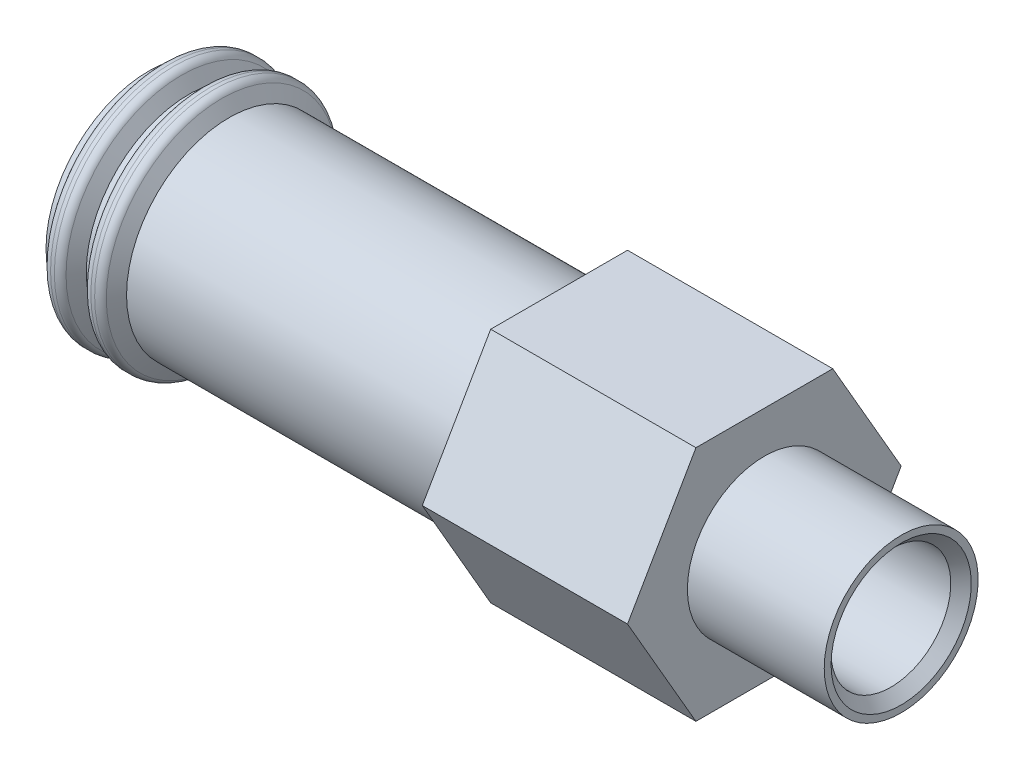
from build123d import *

# Parameters (mm, degrees)
CORTE_EXTRUS_O1_REACH = 20
FILETE1_R             = 0.25
FILETE2_R             = 0.25
CHANFRO1_SIZE         = 0.3


with BuildPart() as part:
    # Esboço1 → Revolução1 (revolve)
    with BuildSketch(Plane.XY):
        Polygon((-13.322649731, 3), (-13.122649731, 3), (-12.833974596, 3.5), (-12.433974596, 3.5), (-12.145299462, 3), (-2.5, 3), (-2.5, 4), (3.5, 4), (3.5, 2.25), (7.5, 2.25), (7.5, 1.75), (-9.200961894, 1.75), (-10.5, 2.5), (-14.5, 2.5), (-14.5, 3), (-14.3, 3), (-14.011324865, 3.5), (-13.611324865, 3.5), align=None)
    revolve(axis=Axis((-29.721905334, 0, 0), (1, 0, 0)))

    # Esboço2 → Corte-extrusão1 (cut, up to next)
    with BuildSketch(Plane(origin=(3.5, 0, 0), x_dir=(0, 0, -1), z_dir=(1, 0, 0)), mode=Mode.PRIVATE) as corte_extrus_o1_sk1:
        with BuildLine():
            Line((-2, 3.464101615), (2, 3.464101615))
            ThreePointArc((2, 3.464101615), (0, 4), (-2, 3.464101615))
        make_face()
    corte_extrus_o1_tool1 = extrude(corte_extrus_o1_sk1.sketch, amount=-CORTE_EXTRUS_O1_REACH, mode=Mode.PRIVATE) & part.part
    add(corte_extrus_o1_tool1.solids().sort_by_distance((3.5, 3.679741, 0))[0], mode=Mode.SUBTRACT)
    # Esboço2 → Corte-extrusão1 (cut, up to next)
    with BuildSketch(Plane(origin=(3.5, 0, 0), x_dir=(0, 0, -1), z_dir=(1, 0, 0)), mode=Mode.PRIVATE) as corte_extrus_o1_sk2:
        with BuildLine():
            Line((-4, 0), (-2, 3.464101615))
            ThreePointArc((-2, 3.464101615), (-3.464101615, 2), (-4, 0))
        make_face()
    corte_extrus_o1_tool2 = extrude(corte_extrus_o1_sk2.sketch, amount=-CORTE_EXTRUS_O1_REACH, mode=Mode.PRIVATE) & part.part
    add(corte_extrus_o1_tool2.solids().sort_by_distance((3.5, 1.839871, 3.18675))[0], mode=Mode.SUBTRACT)
    # Esboço2 → Corte-extrusão1 (cut, up to next)
    with BuildSketch(Plane(origin=(3.5, 0, 0), x_dir=(0, 0, -1), z_dir=(1, 0, 0)), mode=Mode.PRIVATE) as corte_extrus_o1_sk3:
        with BuildLine():
            ThreePointArc((-4, 0), (-3.464101615, -2), (-2, -3.464101615))
            Line((-2, -3.464101615), (-4, 0))
        make_face()
    corte_extrus_o1_tool3 = extrude(corte_extrus_o1_sk3.sketch, amount=-CORTE_EXTRUS_O1_REACH, mode=Mode.PRIVATE) & part.part
    add(corte_extrus_o1_tool3.solids().sort_by_distance((3.5, -1.839871, 3.18675))[0], mode=Mode.SUBTRACT)
    # Esboço2 → Corte-extrusão1 (cut, up to next)
    with BuildSketch(Plane(origin=(3.5, 0, 0), x_dir=(0, 0, -1), z_dir=(1, 0, 0)), mode=Mode.PRIVATE) as corte_extrus_o1_sk4:
        with BuildLine():
            ThreePointArc((-2, -3.464101615), (0, -4), (2, -3.464101615))
            Line((2, -3.464101615), (-2, -3.464101615))
        make_face()
    corte_extrus_o1_tool4 = extrude(corte_extrus_o1_sk4.sketch, amount=-CORTE_EXTRUS_O1_REACH, mode=Mode.PRIVATE) & part.part
    add(corte_extrus_o1_tool4.solids().sort_by_distance((3.5, -3.679741, 0))[0], mode=Mode.SUBTRACT)
    # Esboço2 → Corte-extrusão1 (cut, up to next)
    with BuildSketch(Plane(origin=(3.5, 0, 0), x_dir=(0, 0, -1), z_dir=(1, 0, 0)), mode=Mode.PRIVATE) as corte_extrus_o1_sk5:
        with BuildLine():
            ThreePointArc((2, -3.464101615), (3.464101615, -2), (4, 0))
            Line((4, 0), (2, -3.464101615))
        make_face()
    corte_extrus_o1_tool5 = extrude(corte_extrus_o1_sk5.sketch, amount=-CORTE_EXTRUS_O1_REACH, mode=Mode.PRIVATE) & part.part
    add(corte_extrus_o1_tool5.solids().sort_by_distance((3.5, -1.839871, -3.18675))[0], mode=Mode.SUBTRACT)
    # Esboço2 → Corte-extrusão1 (cut, up to next)
    with BuildSketch(Plane(origin=(3.5, 0, 0), x_dir=(0, 0, -1), z_dir=(1, 0, 0)), mode=Mode.PRIVATE) as corte_extrus_o1_sk6:
        with BuildLine():
            Line((2, 3.464101615), (4, 0))
            ThreePointArc((4, 0), (3.464101615, 2), (2, 3.464101615))
        make_face()
    corte_extrus_o1_tool6 = extrude(corte_extrus_o1_sk6.sketch, amount=-CORTE_EXTRUS_O1_REACH, mode=Mode.PRIVATE) & part.part
    add(corte_extrus_o1_tool6.solids().sort_by_distance((3.5, 1.839871, -3.18675))[0], mode=Mode.SUBTRACT)

    # Filete1
    filete1_edges = [part.edges().sort_by_distance(p)[0] for p in [
        (-14.011324865, -3.5, 0),
        (-13.611324865, -3.5, 0),
    ]]
    fillet(filete1_edges, radius=FILETE1_R)

    # Filete2
    filete2_edges = [part.edges().sort_by_distance(p)[0] for p in [
        (-12.833974596, -3.5, 0),
        (-12.433974596, -3.5, 0),
    ]]
    fillet(filete2_edges, radius=FILETE2_R)

    # Chanfro1
    chanfro1_edges = [part.edges().sort_by_distance(p)[0] for p in [
        (7.5, -1.75, 0),
    ]]
    chamfer(chanfro1_edges, length=CHANFRO1_SIZE)


solid = part.part
